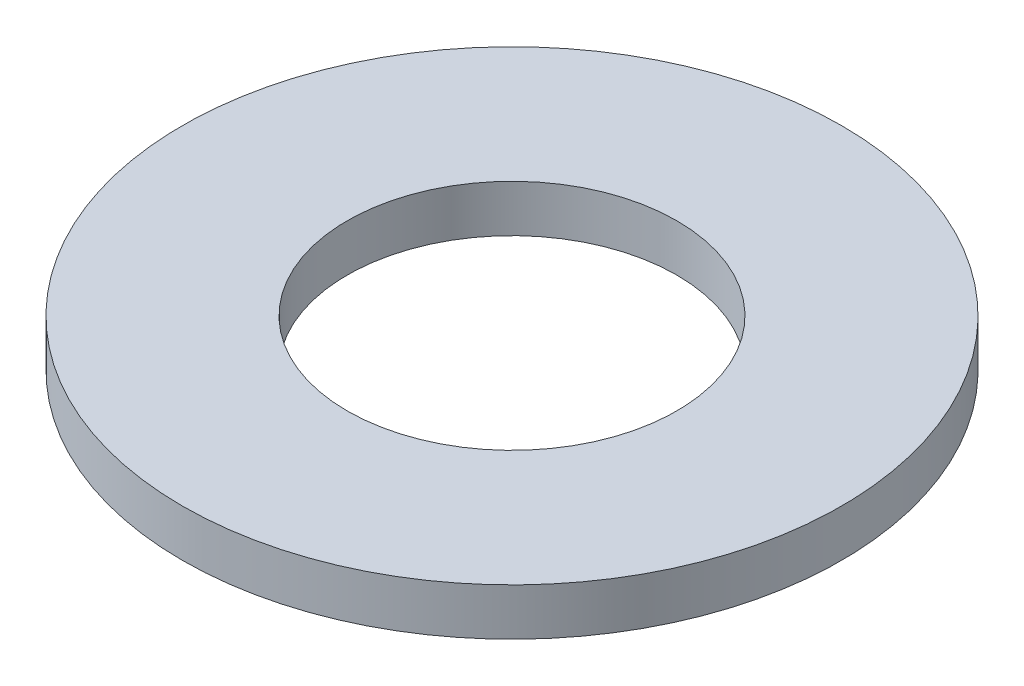
from build123d import *

# Parameters (mm, degrees)
SKICA1_R                = 3.5
SKICA1_R_2              = 1.75
P_IDAT_VYSUNUT_M1_DEPTH = 0.5


with BuildPart() as part:
    # Skica1 → Přidat vysunutím1 (new body)
    with BuildSketch(Plane(origin=(0, 0, 0), x_dir=(1, 0, 0), z_dir=(0, 1, 0))):
        Circle(SKICA1_R)
        Circle(SKICA1_R_2, mode=Mode.SUBTRACT)
    extrude(amount=P_IDAT_VYSUNUT_M1_DEPTH)


solid = part.part
